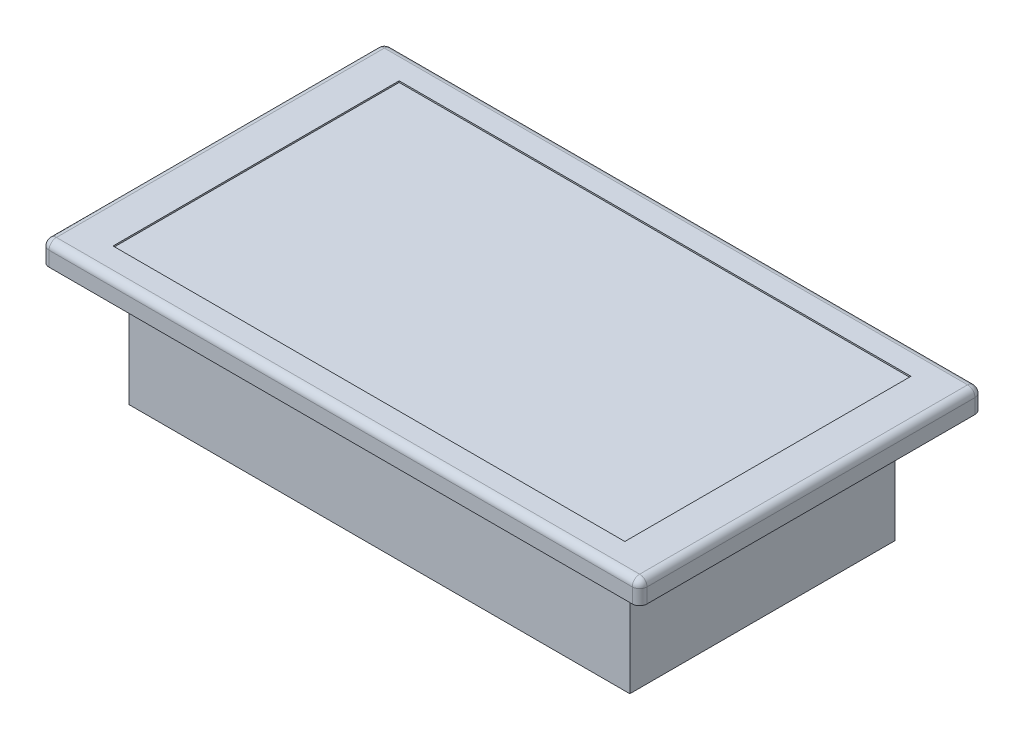
from build123d import *

# Parameters (mm, degrees)
SKETCH1_W           = 86.36
SKETCH1_H           = 45.72
BOSS_EXTRUDE1_DEPTH = 20.32
SKETCH2_W           = 13.191373839
SKETCH2_H           = 25.811253635
CUT_EXTRUDE1_DEPTH  = 15.494
SKETCH3_W           = 103.131055872
SKETCH3_H           = 59.099547652
BOSS_EXTRUDE2_DEPTH = 3.81
FILLET1_R           = 1.27
FILLET2_R           = 1.27
SKETCH4_W           = 88.271220028
SKETCH4_H           = 49.346222858
CUT_EXTRUDE2_DEPTH  = 0.254


with BuildPart() as part:
    # Sketch1 → Boss-Extrude1 (new body)
    with BuildSketch(Plane(origin=(0, 0, 0), x_dir=(1, 0, 0), z_dir=(0, 1, 0))):
        Rectangle(SKETCH1_W, SKETCH1_H)
    extrude(amount=BOSS_EXTRUDE1_DEPTH)

    # Sketch2 → Cut-Extrude1 (cut)
    with BuildSketch(Plane.XZ):
        with Locations((-36.584313081, -0.435427154)):
            Rectangle(SKETCH2_W, SKETCH2_H)
    extrude(amount=-CUT_EXTRUDE1_DEPTH, mode=Mode.SUBTRACT)

    # Sketch3 → Boss-Extrude2 (add)
    with BuildSketch(Plane(origin=(0, 20.32, 0), x_dir=(1, 0, 0), z_dir=(0, 1, 0))):
        Rectangle(SKETCH3_W, SKETCH3_H)
    extrude(amount=BOSS_EXTRUDE2_DEPTH)

    # Fillet1
    fillet1_edges = [part.edges().sort_by_distance(p)[0] for p in [
        (51.565527936, 22.225, 29.549773826),
        (51.565527936, 22.225, -29.549773826),
        (-51.565527936, 22.225, -29.549773826),
        (-51.565527936, 22.225, 29.549773826),
    ]]
    fillet(fillet1_edges, radius=FILLET1_R)

    # Fillet2
    fillet2_edges = [part.edges().sort_by_distance(p)[0] for p in [
        (-51.565527936, 24.13, 0),
        (0, 24.13, -29.549773826),
        (51.565527936, 24.13, 0),
        (0, 24.13, 29.549773826),
        (-51.193553548, 24.13, 29.177799438),
        (51.193553548, 24.13, 29.177799438),
        (51.193553548, 24.13, -29.177799438),
        (-51.193553548, 24.13, -29.177799438),
    ]]
    fillet(fillet2_edges, radius=FILLET2_R)

    # Sketch4 → Cut-Extrude2 (cut)
    with BuildSketch(Plane(origin=(0, 24.13, 0), x_dir=(1, 0, 0), z_dir=(0, 1, 0))):
        Rectangle(SKETCH4_W, SKETCH4_H)
    extrude(amount=-CUT_EXTRUDE2_DEPTH, mode=Mode.SUBTRACT)


solid = part.part
